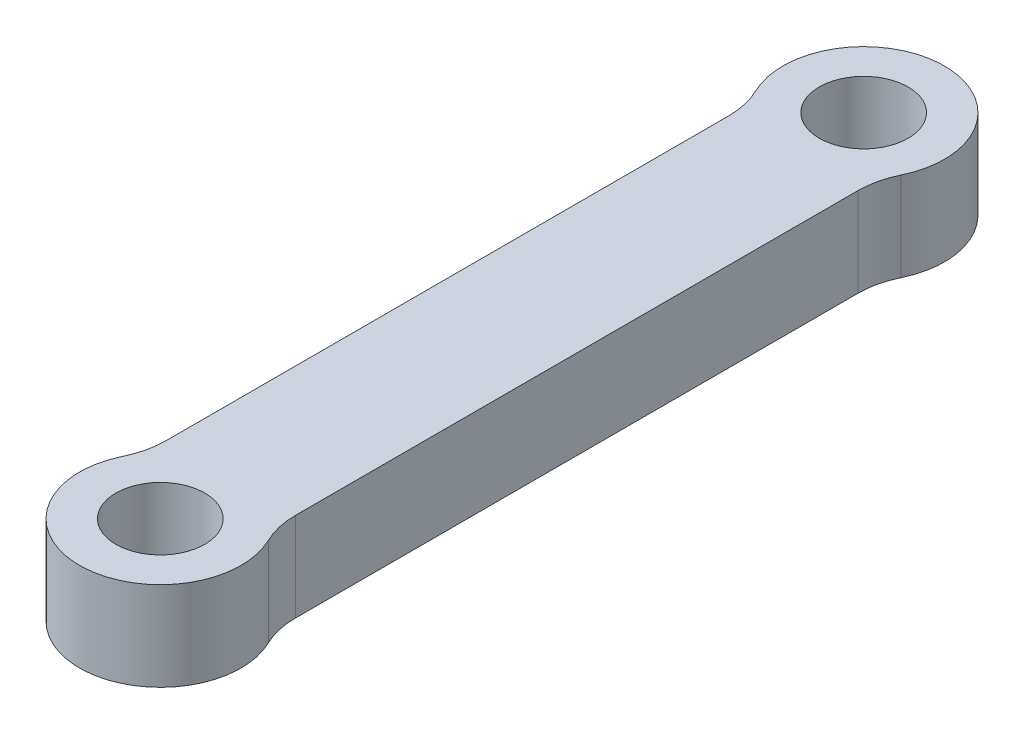
from build123d import *

# Parameters (mm, degrees)
BOSS_EXTRUDE1_DEPTH = 5.5
SKETCH2_R           = 2.75
CUT_EXTRUDE2_DEPTH  = 6.5
SKETCH3_R           = 5
SKETCH3_R_2         = 2.75
BOSS_EXTRUDE2_DEPTH = 5.5
FILLET1_R           = 5


with BuildPart() as part:
    # Sketch1 → Boss-Extrude1 (new body)
    with BuildSketch(Plane(origin=(0, 0, 0), x_dir=(1, 0, 0), z_dir=(0, 1, 0))):
        with BuildLine():
            Line((-4, -21.75), (-4, 21.75))
            ThreePointArc((-4, 21.75), (0, 25.75), (4, 21.75))
            Line((4, 21.75), (4, -21.75))
            ThreePointArc((4, -21.75), (0, -25.75), (-4, -21.75))
        make_face()
    extrude(amount=BOSS_EXTRUDE1_DEPTH)

    # Sketch2 → Cut-Extrude2 (cut, through all)
    with BuildSketch(Plane(origin=(0, 5.5, 0), x_dir=(1, 0, 0), z_dir=(0, 1, 0))):
        with Locations((0, 21.75)):
            Circle(SKETCH2_R)
        with Locations((0, -21.75)):
            Circle(SKETCH2_R)
    extrude(amount=-CUT_EXTRUDE2_DEPTH, mode=Mode.SUBTRACT)

    # Sketch3 → Boss-Extrude2 (add)
    with BuildSketch(Plane(origin=(0, 5.5, 0), x_dir=(1, 0, 0), z_dir=(0, 1, 0))):
        with Locations((0, 21.75)):
            Circle(SKETCH3_R)
        with Locations((0, 21.75)):
            Circle(SKETCH3_R_2, mode=Mode.SUBTRACT)
        with Locations((0, -21.75)):
            Circle(SKETCH3_R)
        with Locations((0, -21.75)):
            Circle(SKETCH3_R_2, mode=Mode.SUBTRACT)
    extrude(amount=-BOSS_EXTRUDE2_DEPTH)

    # Fillet1
    fillet1_edges = [part.edges().sort_by_distance(p)[0] for p in [
        (-4, 2.75, -18.75),
        (4, 2.75, -18.75),
        (-4, 2.75, 18.75),
        (4, 2.75, 18.75),
    ]]
    fillet(fillet1_edges, radius=FILLET1_R)


solid = part.part
